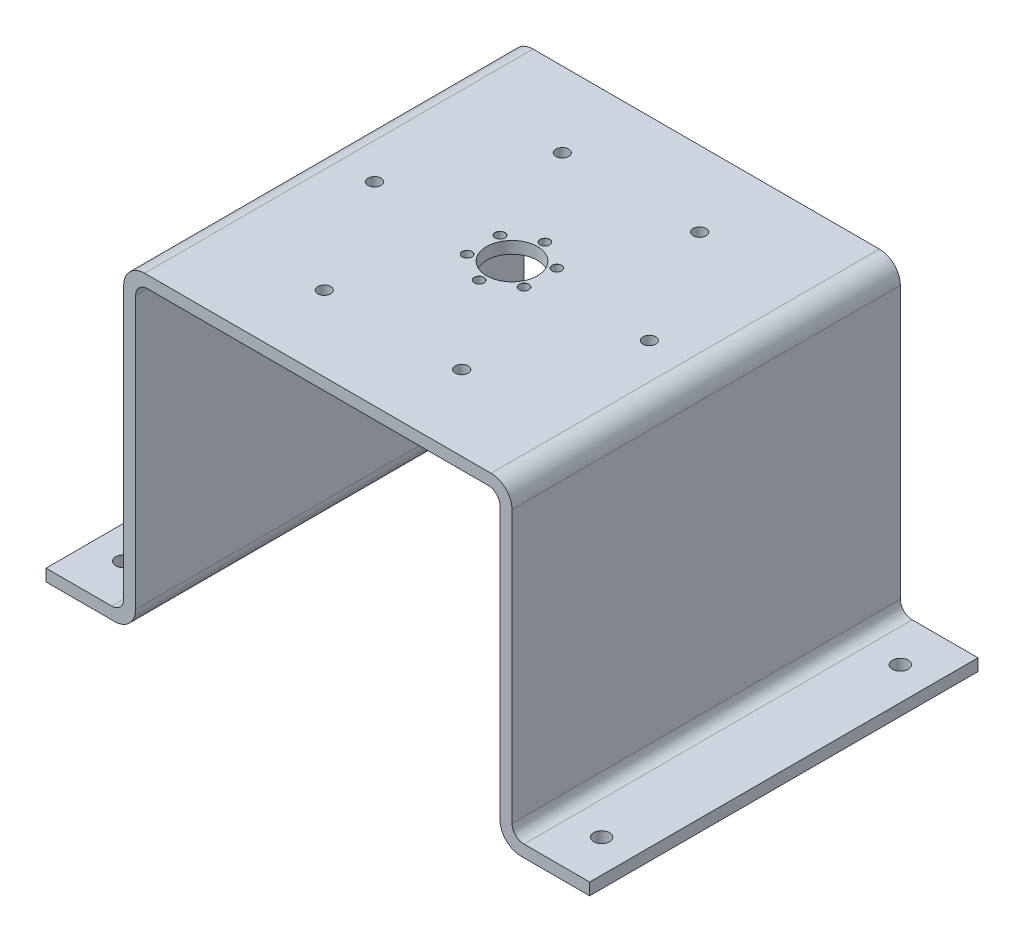
from build123d import *

# Parameters (mm, degrees)
BOSS_EXTRUDE1_DEPTH            = 130
FILLET1_R                      = 4
FILLET2_R                      = 7
SKETCH2_R                      = 8.5
CUT_EXTRUDE1_DEPTH             = 100
M3_CLEARANCE_HOLE1_D           = 3.2
M3_CLEARANCE_HOLE1_CSINK_D     = 3.25
M3_CLEARANCE_HOLE1_CSINK_ANGLE = 90
M4_CLEARANCE_HOLE1_D           = 4.3
M4_CLEARANCE_HOLE1_DEPTH       = 100
M4_CLEARANCE_HOLE1_TIP         = 1.291850331
M5_CLEARANCE_HOLE2_D           = 5.3
M5_CLEARANCE_HOLE2_DEPTH       = 100
M5_CLEARANCE_HOLE2_TIP         = 1.59228064


with BuildPart() as part:
    # Sketch1 → Boss-Extrude1 (new body)
    with BuildSketch(Plane.XY):
        Polygon((0, 4), (26, 4), (26, 106), (156, 106), (156, 4), (182, 4), (182, 0), (152, 0), (152, 102), (30, 102), (30, 0), (0, 0), align=None)
    extrude(amount=BOSS_EXTRUDE1_DEPTH)

    # Fillet1
    fillet1_edges = [part.edges().sort_by_distance(p)[0] for p in [
        (26, 4, 65),
        (156, 4, 65),
        (152, 102, 65),
        (30, 102, 65),
    ]]
    fillet(fillet1_edges, radius=FILLET1_R)

    # Fillet2
    fillet2_edges = [part.edges().sort_by_distance(p)[0] for p in [
        (26, 106, 65),
        (156, 106, 65),
        (152, 0, 65),
        (30, 0, 65),
    ]]
    fillet(fillet2_edges, radius=FILLET2_R)

    # Sketch2 → Cut-Extrude1 (cut)
    with BuildSketch(Plane(origin=(0, 106, 0), x_dir=(1, 0, 0), z_dir=(0, 1, 0))):
        with Locations((91, -65)):
            Circle(SKETCH2_R)
    extrude(amount=-CUT_EXTRUDE1_DEPTH, mode=Mode.SUBTRACT)

    # M3 Clearance Hole1 (through all)
    with Locations(Plane(origin=(0, 106, 0), x_dir=(1, 0, 0), z_dir=(0, 1, 0))):
        with Locations((91, -54), (100.526279442, -59.5), (100.526279442, -70.5), (91, -76), (81.473720558, -70.5), (81.473720558, -59.5), (91, -65)):
            CounterSinkHole(M3_CLEARANCE_HOLE1_D / 2, M3_CLEARANCE_HOLE1_CSINK_D / 2, counter_sink_angle=M3_CLEARANCE_HOLE1_CSINK_ANGLE)

    # M4 Clearance Hole1
    with Locations(Plane(origin=(0, 106, 0), x_dir=(1, 0, 0), z_dir=(0, 1, 0))):
        with Locations((137, -65), (114, -104.837168574), (68, -104.837168574), (45, -65), (68, -25.162831426), (114, -25.162831426), (91, -65)):
            Hole(M4_CLEARANCE_HOLE1_D / 2, depth=M4_CLEARANCE_HOLE1_DEPTH)
            with Locations((0, 0, -(M4_CLEARANCE_HOLE1_DEPTH + M4_CLEARANCE_HOLE1_TIP / 2))):  # 118° drill point
                Cone(0, M4_CLEARANCE_HOLE1_D / 2, M4_CLEARANCE_HOLE1_TIP, mode=Mode.SUBTRACT)

    # M5 Clearance Hole2
    with Locations(Plane(origin=(0, 4, 0), x_dir=(1, 0, 0), z_dir=(0, 1, 0))):
        with Locations((11, -15), (11, -115), (171, -115), (171, -15)):
            Hole(M5_CLEARANCE_HOLE2_D / 2, depth=M5_CLEARANCE_HOLE2_DEPTH)
            with Locations((0, 0, -(M5_CLEARANCE_HOLE2_DEPTH + M5_CLEARANCE_HOLE2_TIP / 2))):  # 118° drill point
                Cone(0, M5_CLEARANCE_HOLE2_D / 2, M5_CLEARANCE_HOLE2_TIP, mode=Mode.SUBTRACT)


solid = part.part
